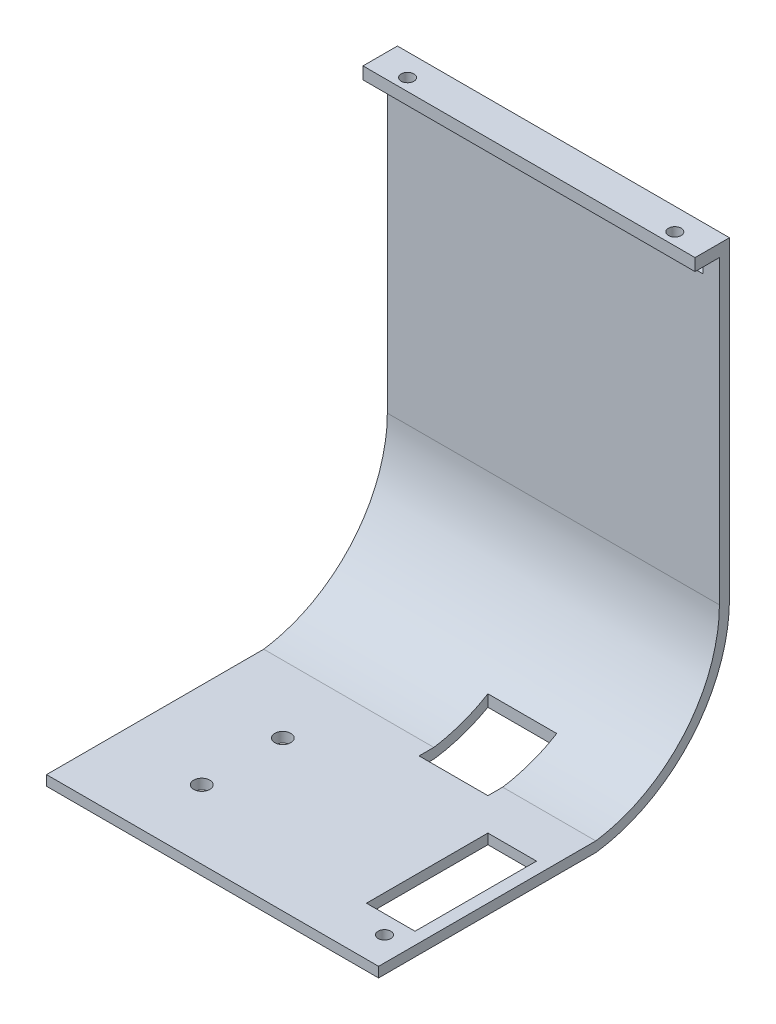
from build123d import *

# Parameters (mm, degrees)
BOSS_EXTRUDE1_DEPTH      = 50
SKETCH3_W                = 92
SKETCH3_H                = 120
BOSS_EXTRUDE2_DEPTH      = 5
SKETCH4_W                = 8.115199035
SKETCH4_H                = 120
BOSS_EXTRUDE3_DEPTH      = 12
BOSS_EXTRUDE4_DEPTH      = 60
SKETCH5_W                = 10
SKETCH5_H                = 2
BOSS_EXTRUDE5_DEPTH      = 20
BOSS_EXTRUDE6_START      = 50
SKETCH5_2_W              = 10
SKETCH5_2_H              = 2
BOSS_EXTRUDE6_DEPTH      = 20
SKETCH6_W                = 92
SKETCH6_H                = 120
BOSS_EXTRUDE7_DEPTH      = 5
SKETCH7_W                = 7
SKETCH7_H                = 10
SKETCH7_R                = 1.6
BOSS_EXTRUDE8_DEPTH      = 3
CUT_EXTRUDE2_DEPTH       = 164.816971038
SKETCH12_W               = 112.5
SKETCH12_H               = 2.5
CUT_EXTRUDE4_DEPTH       = 165.373051319
CUT_EXTRUDE4_DEPTH_BACK  = 165.373051319
SKETCH14_W               = 106
SKETCH14_H               = 1.5
CUT_EXTRUDE5_DEPTH       = 162.085381087
SKETCH15_R               = 1.6
BOSS_EXTRUDE10_DEPTH     = 2
SKETCH16_W               = 87
SKETCH16_H               = 3.364665628
CUT_EXTRUDE6_DEPTH       = 162.085381087
SKETCH17_W               = 10
SKETCH17_H               = 2
CUT_EXTRUDE7_DEPTH       = 70
SKETCH19_W               = 7
SKETCH19_H               = 10
SKETCH19_R               = 1.6
BOSS_EXTRUDE11_DEPTH     = 3.5
SKETCH21_W               = 7
SKETCH21_H               = 10
SKETCH21_R               = 1.6
BOSS_EXTRUDE13_DEPTH     = 3.5
SKETCH22_W               = 9.5
SKETCH22_H               = 117.5
CUT_EXTRUDE8_DEPTH       = 186.007067988
CUT_EXTRUDE9_DEPTH       = 156.903445849
CUT_EXTRUDE10_START      = -8.115199
SKETCH26_W               = 12
SKETCH26_H               = 12
CUT_EXTRUDE10_DEPTH      = 8.115199
SKETCH27_R               = 1.575
CUT_EXTRUDE11_DEPTH      = 6
SKETCH28_W               = 108.793725607
SKETCH28_H               = 128.432707594
CUT_EXTRUDE12_DEPTH      = 155.300842512
CUT_EXTRUDE13_DEPTH      = 127.920694069
CUT_EXTRUDE14_DEPTH      = 130.130747828
BOSS_EXTRUDE14_DEPTH     = 79.5
SKETCH32_W               = 2.5
SKETCH32_H               = 2.5
CUT_EXTRUDE15_DEPTH      = 153.946069092
SKETCH35_R               = 1.575
CUT_EXTRUDE16_DEPTH      = 153.405708721
SKETCH36_W               = 82
SKETCH36_H               = 3
BOSS_EXTRUDE15_DEPTH     = 6
CUT_EXTRUDE17_REACH      = 154.406
SKETCH37_R               = 1.575
SKETCH38_W               = 17
SKETCH38_H               = 17
CUT_EXTRUDE18_DEPTH      = 153.405708721
CUT_EXTRUDE18_DEPTH_BACK = 153.405708721
SKETCH39_W               = 12
SKETCH39_H               = 30
CUT_EXTRUDE19_DEPTH      = 153.405708721
CUT_EXTRUDE20_REACH      = 168.956
SKETCH40_W               = 8
SKETCH40_H               = 5
CUT_EXTRUDE22_REACH      = 154.406
SKETCH42_R               = 2


with BuildPart() as part:
    # Sketch2 → Boss-Extrude1 (new body)
    with BuildSketch(Plane.XY):
        Polygon((0, 0), (0, 115), (82, 115), (82, 0), (87, 0), (87, 120), (-5, 120), (-5, 0), align=None)
    extrude(amount=BOSS_EXTRUDE1_DEPTH)

    # Sketch3 → Boss-Extrude2 (add)
    with BuildSketch(Plane.XY.offset(50)):
        with Locations((41, 60)):
            Rectangle(SKETCH3_W, SKETCH3_H)
    extrude(amount=BOSS_EXTRUDE2_DEPTH)

    # Sketch4 → Boss-Extrude3 (add)
    with BuildSketch(Plane.ZY.offset(-82)):
        with Locations((45.942400483, 60)):
            Rectangle(SKETCH4_W, SKETCH4_H)
    extrude(amount=BOSS_EXTRUDE3_DEPTH)

    # Sketch2_2 → Boss-Extrude4 (add)
    with BuildSketch(Plane.XY):
        Polygon((0, 0), (0, 115), (82, 115), (82, 0), (87, 0), (87, 120), (-5, 120), (-5, 0), align=None)
    extrude(amount=-BOSS_EXTRUDE4_DEPTH)

    # Sketch5 → Boss-Extrude5 (add)
    with BuildSketch(Plane.XZ.offset(-115)):
        with Locations((5, 7.889828052)):
            Rectangle(SKETCH5_W, SKETCH5_H)
        with Locations((5, 2.689828052)):
            Rectangle(SKETCH5_W, SKETCH5_H)
        with Locations((77, 2.689828052)):
            Rectangle(SKETCH5_W, SKETCH5_H)
        with Locations((77, 7.889828052)):
            Rectangle(SKETCH5_W, SKETCH5_H)
    extrude(amount=BOSS_EXTRUDE5_DEPTH)

    # Sketch5_2 → Boss-Extrude6 (add)
    with BuildSketch(Plane.XZ.offset(-115).offset(BOSS_EXTRUDE6_START)):
        with Locations((5, 7.889828052)):
            Rectangle(SKETCH5_2_W, SKETCH5_2_H)
        with Locations((5, 2.689828052)):
            Rectangle(SKETCH5_2_W, SKETCH5_2_H)
        with Locations((77, 2.689828052)):
            Rectangle(SKETCH5_2_W, SKETCH5_2_H)
        with Locations((77, 7.889828052)):
            Rectangle(SKETCH5_2_W, SKETCH5_2_H)
    extrude(amount=BOSS_EXTRUDE6_DEPTH)

    # Sketch6 → Boss-Extrude7 (add)
    with BuildSketch(Plane(origin=(0, 0, -60), x_dir=(-1, 0, 0), z_dir=(0, 0, -1))):
        with Locations((-41, 60)):
            Rectangle(SKETCH6_W, SKETCH6_H)
    extrude(amount=-BOSS_EXTRUDE7_DEPTH)

    # Sketch7 → Boss-Extrude8 (add)
    with BuildSketch(Plane.XY.offset(55)):
        with Locations((90.5, 115)):
            Rectangle(SKETCH7_W, SKETCH7_H)
        with Locations((90.472155735, 113.006992181)):
            Circle(SKETCH7_R, mode=Mode.SUBTRACT)
        with Locations((-8.5, 115)):
            Rectangle(SKETCH7_W, SKETCH7_H)
        with Locations(Location((-8.472155735, 113.006992181, 0), (0, 0, 180))):
            Circle(SKETCH7_R, mode=Mode.SUBTRACT)
        with Locations((-8.5, 5)):
            Rectangle(SKETCH7_W, SKETCH7_H)
        with Locations((-8.472155735, 6.993007819)):
            Circle(SKETCH7_R, mode=Mode.SUBTRACT)
        with Locations((90.5, 5)):
            Rectangle(SKETCH7_W, SKETCH7_H)
        with Locations(Location((90.472155735, 6.993007819, 0), (0, 0, 180))):
            Circle(SKETCH7_R, mode=Mode.SUBTRACT)
    extrude(amount=-BOSS_EXTRUDE8_DEPTH)

    # Sketch11 → Cut-Extrude2 (cut, through all)
    with BuildSketch(Plane.XZ):
        Polygon((-5, 52), (-2.5, 52), (-2.5, -57.5), (84.5, -57.5), (84.5, 52), (87, 52), (87, -60), (-5, -60), align=None)
    extrude(amount=-CUT_EXTRUDE2_DEPTH, mode=Mode.SUBTRACT)

    # Sketch12 → Cut-Extrude4 (cut, two sides)
    with BuildSketch(Plane.ZY.offset(2.5)) as cut_extrude4_sk:
        with Locations((-1.25, 118.75)):
            Rectangle(SKETCH12_W, SKETCH12_H)
    extrude(amount=CUT_EXTRUDE4_DEPTH, mode=Mode.SUBTRACT)
    extrude(cut_extrude4_sk.sketch, amount=-CUT_EXTRUDE4_DEPTH_BACK, mode=Mode.SUBTRACT)

    # Sketch14 → Cut-Extrude5 (cut, through all)
    with BuildSketch(Plane.XZ):
        with Locations((41, 54.25)):
            Rectangle(SKETCH14_W, SKETCH14_H)
    extrude(amount=-CUT_EXTRUDE5_DEPTH, mode=Mode.SUBTRACT)

    # Sketch15 → Boss-Extrude10 (add)
    with BuildSketch(Plane(origin=(0, 0, 52), x_dir=(-1, 0, 0), z_dir=(0, 0, -1))):
        Polygon((-84.5, 117.5), (-94, 117.5), (-94, 110), (-87, 110), (-87, 10), (-94, 10), (-94, 0), (-84.5, 0), align=None)
        with Locations((-90.472155735, 113.006992181)):
            Circle(SKETCH15_R, mode=Mode.SUBTRACT)
        with Locations((-90.472155735, 6.993007819)):
            Circle(SKETCH15_R, mode=Mode.SUBTRACT)
        Polygon((2.5, 0), (2.5, 117.5), (12, 117.5), (12, 110), (5, 110), (5, 10), (12, 10), (12, 0), align=None)
        with Locations(Location((8.472155735, 113.006992181, 0), (0, 0, 180))):
            Circle(SKETCH15_R, mode=Mode.SUBTRACT)
        with Locations(Location((8.472155735, 6.993007819, 0), (0, 0, 180))):
            Circle(SKETCH15_R, mode=Mode.SUBTRACT)
    extrude(amount=BOSS_EXTRUDE10_DEPTH)

    # Sketch16 → Cut-Extrude6 (cut, through all)
    with BuildSketch(Plane.XZ):
        with Locations((41, -55.817667186)):
            Rectangle(SKETCH16_W, SKETCH16_H)
    extrude(amount=-CUT_EXTRUDE6_DEPTH, mode=Mode.SUBTRACT)

    # Sketch17 → Cut-Extrude7 (cut)
    with BuildSketch(Plane.XZ.offset(-45)):
        with Locations((5, 2.689828052)):
            Rectangle(SKETCH17_W, SKETCH17_H)
        with Locations((77, 2.689828052)):
            Rectangle(SKETCH17_W, SKETCH17_H)
    extrude(amount=-CUT_EXTRUDE7_DEPTH, mode=Mode.SUBTRACT)

    # Sketch19 → Boss-Extrude11 (add)
    with BuildSketch(Plane.XZ):
        with Locations((88, -49.135334372)):
            Rectangle(SKETCH19_W, SKETCH19_H)
        with Locations((87.901562489, -49.234834013)):
            Circle(SKETCH19_R, mode=Mode.SUBTRACT)
        with Locations((-6, -49.135334372)):
            Rectangle(SKETCH19_W, SKETCH19_H)
        with Locations(Location((-5.901562489, -49.234834013, 0), (0, 0, 180))):
            Circle(SKETCH19_R, mode=Mode.SUBTRACT)
        with Locations((-6, 34.080676656)):
            Rectangle(SKETCH19_W, SKETCH19_H)
        with Locations((-5.901562489, 34.180176298)):
            Circle(SKETCH19_R, mode=Mode.SUBTRACT)
        with Locations((88, 34.080676656)):
            Rectangle(SKETCH19_W, SKETCH19_H)
        with Locations(Location((87.901562489, 34.180176298, 0), (0, 0, 180))):
            Circle(SKETCH19_R, mode=Mode.SUBTRACT)
    extrude(amount=-BOSS_EXTRUDE11_DEPTH)

    # Sketch21 → Boss-Extrude13 (add)
    with BuildSketch(Plane(origin=(0, 0, -54.135334372), x_dir=(-1, 0, 0), z_dir=(0, 0, -1))):
        with Locations((-88, 112.5)):
            Rectangle(SKETCH21_W, SKETCH21_H)
        with Locations((-87.460864154, 112.996655596)):
            Circle(SKETCH21_R, mode=Mode.SUBTRACT)
        with Locations((6, 112.5)):
            Rectangle(SKETCH21_W, SKETCH21_H)
        with Locations(Location((5.460864154, 112.996655596, 0), (0, 0, 180))):
            Circle(SKETCH21_R, mode=Mode.SUBTRACT)
        with Locations((6, 17.859776919)):
            Rectangle(SKETCH21_W, SKETCH21_H)
        with Locations((5.460864154, 17.363121322)):
            Circle(SKETCH21_R, mode=Mode.SUBTRACT)
        with Locations((-88, 17.859776919)):
            Rectangle(SKETCH21_W, SKETCH21_H)
        with Locations(Location((-87.460864154, 17.363121322, 0), (0, 0, 180))):
            Circle(SKETCH21_R, mode=Mode.SUBTRACT)
    extrude(amount=-BOSS_EXTRUDE13_DEPTH)

    # Sketch22 → Cut-Extrude8 (cut, through all)
    with BuildSketch(Plane(origin=(0, 0, -54.135334372), x_dir=(-1, 0, 0), z_dir=(0, 0, -1))):
        with Locations((7.25, 58.75)):
            Rectangle(SKETCH22_W, SKETCH22_H)
        with Locations((-89.25, 58.75)):
            Rectangle(SKETCH22_W, SKETCH22_H)
    extrude(amount=-CUT_EXTRUDE8_DEPTH, mode=Mode.SUBTRACT)

    # Sketch24 → Cut-Extrude9 (cut, through all)
    with BuildSketch(Plane.ZY.offset(2.5)):
        with BuildLine():
            Line((-33.153862192, 117.5), (-33.153862192, 37.737088179))
            ThreePointArc((-33.153862192, 37.737088179), (-23.795591024, 12.725573197), (-0.317667186, 0))
            Line((-0.317667186, 0), (-54.135334372, 0))
            Line((-54.135334372, 0), (-54.135334372, 117.5))
            Line((-54.135334372, 117.5), (-33.153862192, 117.5))
        make_face()
    extrude(amount=-CUT_EXTRUDE9_DEPTH, mode=Mode.SUBTRACT)

    # Sketch26 → Cut-Extrude10 (cut)
    with BuildSketch(Plane(origin=(0, 0, 41.884800965), x_dir=(-1, 0, 0), z_dir=(0, 0, -1)).offset(CUT_EXTRUDE10_START)):
        with Locations((-76, 12)):
            Rectangle(SKETCH26_W, SKETCH26_H)
    extrude(amount=CUT_EXTRUDE10_DEPTH, mode=Mode.SUBTRACT)

    # Sketch27 → Cut-Extrude11 (cut)
    with BuildSketch(Plane.XZ):
        with Locations((76, 46.036602525)):
            Circle(SKETCH27_R)
    extrude(amount=-CUT_EXTRUDE11_DEPTH, mode=Mode.SUBTRACT)

    # Sketch28 → Cut-Extrude12 (cut, through all)
    with BuildSketch(Plane.ZY.offset(-82)):
        with Locations((9.705474095, 56.879620763)):
            Rectangle(SKETCH28_W, SKETCH28_H)
    extrude(amount=CUT_EXTRUDE12_DEPTH, mode=Mode.SUBTRACT)

    # 3DSketch1 → Cut-Extrude13 (cut, through all)
    with BuildSketch(Plane(origin=(82, 2.5, -0.143383403), x_dir=(0, 0.9103450776109693, 0.41385002074360044), z_dir=(-1, 0, 0))):
        with BuildLine():
            Line((0, 0), (21.165690282, -46.558127334))
            Line((21.165690282, -46.558127334), (123.579511514, 0))
            Line((123.579511514, 0), (89.787058952, 74.333191514))
            Line((89.787058952, 74.333191514), (19.451147493, 42.357933854))
            add(Edge.make_bspline(
                [(19.451147493, 42.357933854), (19.073503164, 42.186253777), (18.695858835, 42.0145737), (18.319593589, 41.840000931), (17.199072345, 41.298926476), (16.11578633, 40.679749356), (15.408613466, 40.238696045), (13.674397883, 39.081500683), (12.014903876, 37.828173433), (11.050269163, 37.039177313), (9.191446964, 35.382400956), (7.490166914, 33.558487206), (6.680531728, 32.608352946), (5.146509637, 30.638943579), (3.789461316, 28.545680375), (3.156882667, 27.470506499), (1.98702053, 25.26791657), (1.014556989, 22.97052703), (0.57888296, 21.801225298), (-0.188933435, 19.427593794), (-0.744854137, 16.996277974), (-0.9697392, 15.769218079), (-1.313156023, 13.298332506), (-1.443460783, 10.805991744), (-1.45351547, 9.557983588), (-1.372539383, 7.404412729), (-1.116186803, 5.266410588), (-0.980158798, 4.36913409), (-0.731931827, 2.991727413), (-0.431750654, 1.625547457), (-0.317973289, 1.147373929), (-0.183595556, 0.63163023), (-0.035183671, 0.119959589), (-0.023505149, 0.079958731), (-0.011772046, 0.039973715), (0, 0)],
                knots=[0, 0, 0, 0, 0, 0, 0.040869514, 0.040869514, 0.040869514, 0.122608541, 0.122608541, 0.122608541, 0.245217083, 0.245217083, 0.245217083, 0.367825624, 0.367825624, 0.367825624, 0.490434166, 0.490434166, 0.490434166, 0.613042707, 0.613042707, 0.613042707, 0.735651248, 0.735651248, 0.735651248, 0.85825979, 0.85825979, 0.85825979, 0.947511927, 0.947511927, 0.947511927, 0.995894551, 0.995894551, 0.995894551, 1, 1, 1, 1, 1, 1], degree=5))
        make_face()
    extrude(amount=-CUT_EXTRUDE13_DEPTH, mode=Mode.SUBTRACT)

    # Sketch29 → Cut-Extrude14 (cut, through all)
    with BuildSketch(Plane.ZY.offset(-82)):
        Polygon((-30.653862192, 115), (-30.653862192, 117.5), (53.5, 117.5), (53.5, 2.5), (51, 2.5), (51, 115), align=None)
    extrude(amount=-CUT_EXTRUDE14_DEPTH, mode=Mode.SUBTRACT)

    # Sketch31 → Boss-Extrude14 (add)
    with BuildSketch(Plane.ZY.offset(-82)):
        with BuildLine():
            Line((-30.653862192, 37.737088179), (-30.653862192, 117.5))
            Line((-30.653862192, 117.5), (-33.153862192, 117.5))
            Line((-33.153862192, 117.5), (-33.153862192, 37.737088179))
            ThreePointArc((-33.153862192, 37.737088179), (-23.795591024, 12.725573197), (-0.317667186, 0))
            Line((-0.317667186, 0), (53.5, 0))
            Line((53.5, 0), (53.5, 2.5))
            Line((53.5, 2.5), (-0.143383403, 2.5))
            add(Edge.make_bspline(
                [(-0.143383403, 2.5), (-0.184645139, 2.505826499), (-0.225901047, 2.511693126), (-0.267148788, 2.517615997), (-0.794365899, 2.594264873), (-1.319482864, 2.685375306), (-1.801872547, 2.779690766), (-3.169797729, 3.071815916), (-4.526441855, 3.415883496), (-5.399568291, 3.66338897), (-7.451979536, 4.31483189), (-9.445984122, 5.132371053), (-10.577941071, 5.658012489), (-12.792904588, 6.808090062), (-14.900140047, 8.143293922), (-15.924119294, 8.855835695), (-17.907387889, 10.368115472), (-19.750450814, 12.049420794), (-20.634615184, 12.929950049), (-22.323578387, 14.766002155), (-23.844547817, 16.742522281), (-24.561534376, 17.763347871), (-25.905511754, 19.865027151), (-27.063498802, 22.076556717), (-27.593381311, 23.206817207), (-28.549697431, 25.510395869), (-29.288662027, 27.888222438), (-29.607706664, 29.092898961), (-30.061885328, 31.12230067), (-30.397627275, 33.179940614), (-30.506474481, 34.006241873), (-30.621821385, 35.248652427), (-30.650658111, 36.4926371), (-30.653862192, 36.907415259), (-30.653862192, 37.322251719), (-30.653862192, 37.737088179)],
                knots=[0, 0, 0, 0, 0, 0, 0.004105449, 0.004105449, 0.004105449, 0.052488073, 0.052488073, 0.052488073, 0.14174021, 0.14174021, 0.14174021, 0.264348752, 0.264348752, 0.264348752, 0.386957293, 0.386957293, 0.386957293, 0.509565834, 0.509565834, 0.509565834, 0.632174376, 0.632174376, 0.632174376, 0.754782917, 0.754782917, 0.754782917, 0.877391459, 0.877391459, 0.877391459, 0.959130486, 0.959130486, 0.959130486, 1, 1, 1, 1, 1, 1], degree=5))
        make_face()
    extrude(amount=BOSS_EXTRUDE14_DEPTH)

    # Sketch32 → Cut-Extrude15 (cut, through all)
    with BuildSketch(Plane.ZY.offset(-2.5)):
        with Locations((-31.903862192, 116.25)):
            Rectangle(SKETCH32_W, SKETCH32_H)
    extrude(amount=-CUT_EXTRUDE15_DEPTH, mode=Mode.SUBTRACT)

    # Sketch35 → Cut-Extrude16 (cut, through all)
    with BuildSketch(Plane.XZ):
        with Locations((78.5, 46.04)):
            Circle(SKETCH35_R)
    extrude(amount=-CUT_EXTRUDE16_DEPTH, mode=Mode.SUBTRACT)

    # Sketch36 → Boss-Extrude15 (add)
    with BuildSketch(Plane.XY.offset(-30.653862192)):
        with Locations((43.5, 113.5)):
            Rectangle(SKETCH36_W, SKETCH36_H)
    extrude(amount=BOSS_EXTRUDE15_DEPTH)

    # Sketch37 → Cut-Extrude17 (cut, up to next)
    with BuildSketch(Plane(origin=(0, 115, 0), x_dir=(1, 0, 0), z_dir=(0, 1, 0)), mode=Mode.PRIVATE) as cut_extrude17_sk1:
        with Locations(Location((10.5, 27.653862192, 0), (0, 0, 270))):
            Circle(SKETCH37_R)
    cut_extrude17_tool1 = extrude(cut_extrude17_sk1.sketch, amount=-CUT_EXTRUDE17_REACH, mode=Mode.PRIVATE) & part.part
    # Sketch37 → Cut-Extrude17 (cut, up to next)
    with BuildSketch(Plane(origin=(0, 115, 0), x_dir=(1, 0, 0), z_dir=(0, 1, 0)), mode=Mode.PRIVATE) as cut_extrude17_sk2:
        with Locations(Location((76.5, 27.653862192, 0), (0, 0, 270))):
            Circle(SKETCH37_R)
    cut_extrude17_tool2 = extrude(cut_extrude17_sk2.sketch, amount=-CUT_EXTRUDE17_REACH, mode=Mode.PRIVATE) & part.part
    add(cut_extrude17_tool1.solids().sort_by_distance((10.5, 115, -27.653862))[0], mode=Mode.SUBTRACT)
    add(cut_extrude17_tool2.solids().sort_by_distance((76.5, 115, -27.653862))[0], mode=Mode.SUBTRACT)

    # Sketch38 → Cut-Extrude18 (cut, two sides)
    with BuildSketch(Plane.XZ) as cut_extrude18_sk:
        with Locations((53, -5)):
            Rectangle(SKETCH38_W, SKETCH38_H)
    extrude(amount=CUT_EXTRUDE18_DEPTH, mode=Mode.SUBTRACT)
    extrude(cut_extrude18_sk.sketch, amount=-CUT_EXTRUDE18_DEPTH_BACK, mode=Mode.SUBTRACT)

    # Sketch39 → Cut-Extrude19 (cut, through all)
    with BuildSketch(Plane.XZ):
        with Locations((75.5, 26.5)):
            Rectangle(SKETCH39_W, SKETCH39_H)
    extrude(amount=-CUT_EXTRUDE19_DEPTH, mode=Mode.SUBTRACT)

    # Sketch40 → Cut-Extrude20 (cut, up to next)
    with BuildSketch(Plane(origin=(0, 0, -33.153862192), x_dir=(-1, 0, 0), z_dir=(0, 0, -1)), mode=Mode.PRIVATE) as cut_extrude20_sk1:
        with Locations((-76.5, 109)):
            Rectangle(SKETCH40_W, SKETCH40_H)
    cut_extrude20_tool1 = extrude(cut_extrude20_sk1.sketch, amount=-CUT_EXTRUDE20_REACH, mode=Mode.PRIVATE) & part.part
    # Sketch40 → Cut-Extrude20 (cut, up to next)
    with BuildSketch(Plane(origin=(0, 0, -33.153862192), x_dir=(-1, 0, 0), z_dir=(0, 0, -1)), mode=Mode.PRIVATE) as cut_extrude20_sk2:
        with Locations((-10.5, 109)):
            Rectangle(SKETCH40_W, SKETCH40_H)
    cut_extrude20_tool2 = extrude(cut_extrude20_sk2.sketch, amount=-CUT_EXTRUDE20_REACH, mode=Mode.PRIVATE) & part.part
    add(cut_extrude20_tool1.solids().sort_by_distance((76.5, 109, -33.153862))[0], mode=Mode.SUBTRACT)
    add(cut_extrude20_tool2.solids().sort_by_distance((10.5, 109, -33.153862))[0], mode=Mode.SUBTRACT)

    # Sketch42 → Cut-Extrude22 (cut, up to next)
    with BuildSketch(Plane.XZ, mode=Mode.PRIVATE) as cut_extrude22_sk1:
        with Locations((23.844019172, 36.5)):
            Circle(SKETCH42_R)
    cut_extrude22_tool1 = extrude(cut_extrude22_sk1.sketch, amount=-CUT_EXTRUDE22_REACH, mode=Mode.PRIVATE) & part.part
    # Sketch42 → Cut-Extrude22 (cut, up to next)
    with BuildSketch(Plane.XZ, mode=Mode.PRIVATE) as cut_extrude22_sk2:
        with Locations((23.844019172, 16.5)):
            Circle(SKETCH42_R)
    cut_extrude22_tool2 = extrude(cut_extrude22_sk2.sketch, amount=-CUT_EXTRUDE22_REACH, mode=Mode.PRIVATE) & part.part
    add(cut_extrude22_tool1.solids().sort_by_distance((23.844019, 0, 36.5))[0], mode=Mode.SUBTRACT)
    add(cut_extrude22_tool2.solids().sort_by_distance((23.844019, 0, 16.5))[0], mode=Mode.SUBTRACT)


solid = part.part
